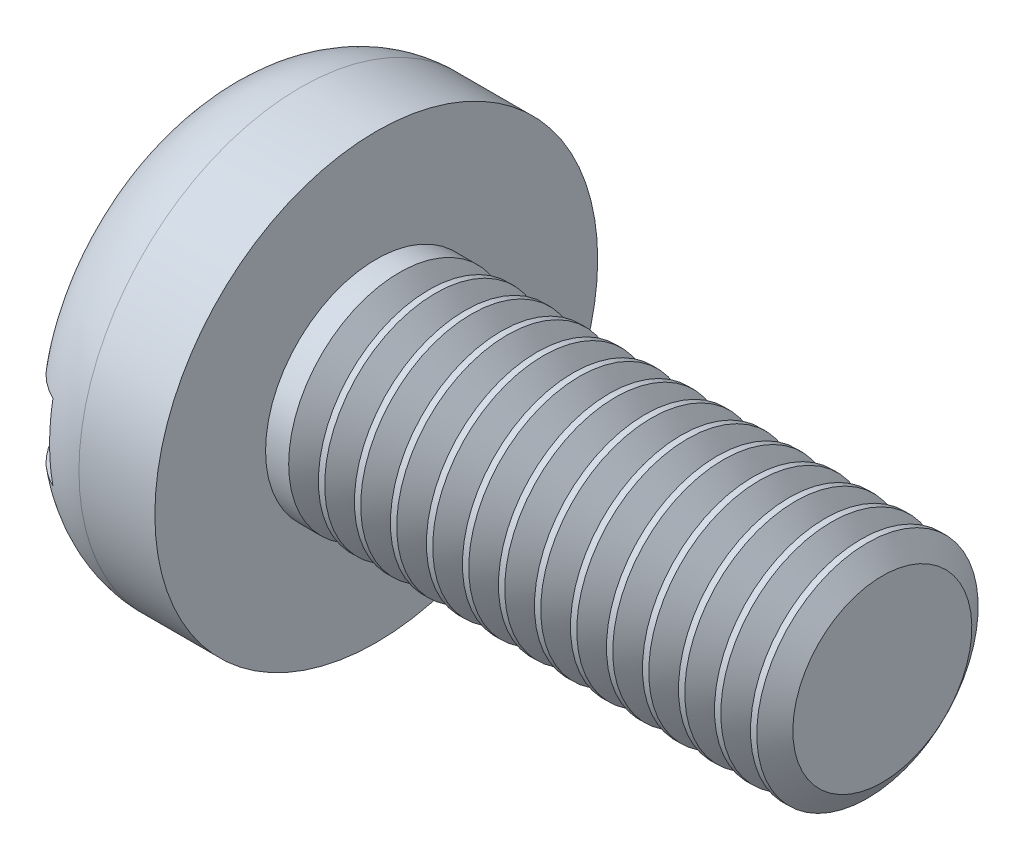
from build123d import *

# Parameters (mm, degrees)
SKETCH2_W       = 7
SKETCH2_H       = 1.2
SLOT_DEPTH      = 0.8
THDSCHPAT_COUNT = 14
THDSCHPAT_PITCH = 0.569230769


with BuildPart() as part:
    # BodySke → Base-Revolve (revolve)
    with BuildSketch(Plane.XY):
        with BuildLine():
            Line((2.6, 1.75), (2.6, 3.5))
            Line((2.6, 3.5), (1.4, 3.5))
            ThreePointArc((1.4, 3.5), (0.410050506, 3.089949494), (0, 2.1))
            Line((0, 2.1), (0, 0))
            Line((0, 0), (10.6, 0))
            Line((10.6, 0), (10.6, 1.75))
            Line((10.6, 1.75), (2.6, 1.75))
        make_face()
    revolve(axis=Axis((-25.4, 0, 0), (1, 0, 0)))

    # Sketch2 → Slot (cut)
    with BuildSketch(Plane(origin=(0, 0, 0), x_dir=(0, 0, -1), z_dir=(1, 0, 0))):
        Rectangle(SKETCH2_W, SKETCH2_H)
    extrude(amount=SLOT_DEPTH, mode=Mode.SUBTRACT)

    # ThdSchSke → ThreadSchematic (revolve, cut)
    with BuildSketch(Plane.XY):
        Polygon((3.2, -1.4145), (2.965080371, -1.75), (2.965080371, -2.1875), (3.434919629, -2.1875), (3.434919629, -1.75), align=None)
    threadschematic = revolve(axis=Axis((-3.175, 0, 0), (1, 0, 0)), mode=Mode.SUBTRACT)

    # ThdSchPat: ThreadSchematic ×14
    with Locations(*[(i * THDSCHPAT_PITCH, 0, 0) for i in range(1, THDSCHPAT_COUNT)]):
        add(threadschematic, mode=Mode.SUBTRACT)


solid = part.part
